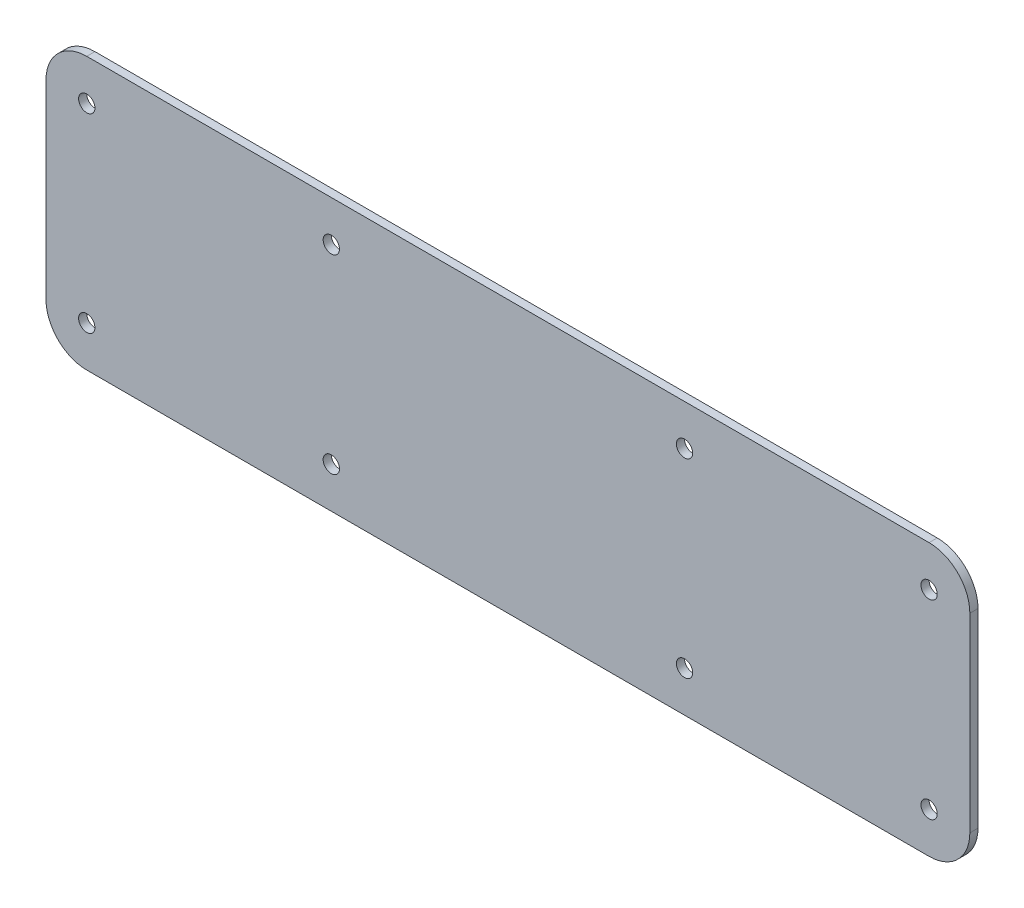
from build123d import *

# Parameters (mm, degrees)
SKETCH1_R           = 1.5
BOSS_EXTRUDE1_DEPTH = 1.5


with BuildPart() as part:
    # Sketch1 → Boss-Extrude1 (new body)
    with BuildSketch(Plane.XY):
        with BuildLine():
            Line((-77.5, -25), (77.5, -25))
            ThreePointArc((77.5, -25), (82.803300859, -22.803300859), (85, -17.5))
            Line((85, -17.5), (85, 17.5))
            ThreePointArc((85, 17.5), (82.803300859, 22.803300859), (77.5, 25))
            Line((77.5, 25), (-77.5, 25))
            ThreePointArc((-77.5, 25), (-82.803300859, 22.803300859), (-85, 17.5))
            Line((-85, 17.5), (-85, -17.5))
            ThreePointArc((-85, -17.5), (-82.803300859, -22.803300859), (-77.5, -25))
        make_face()
        with Locations((-32.5, 17.5)):
            Circle(SKETCH1_R, mode=Mode.SUBTRACT)
        with Locations((32.5, 17.5)):
            Circle(SKETCH1_R, mode=Mode.SUBTRACT)
        with Locations((77.5, 17.5)):
            Circle(SKETCH1_R, mode=Mode.SUBTRACT)
        with Locations((-77.5, 17.5)):
            Circle(SKETCH1_R, mode=Mode.SUBTRACT)
        with Locations((-77.5, -17.5)):
            Circle(SKETCH1_R, mode=Mode.SUBTRACT)
        with Locations((-32.5, -17.5)):
            Circle(SKETCH1_R, mode=Mode.SUBTRACT)
        with Locations((32.5, -17.5)):
            Circle(SKETCH1_R, mode=Mode.SUBTRACT)
        with Locations((77.5, -17.5)):
            Circle(SKETCH1_R, mode=Mode.SUBTRACT)
    extrude(amount=BOSS_EXTRUDE1_DEPTH)


solid = part.part
